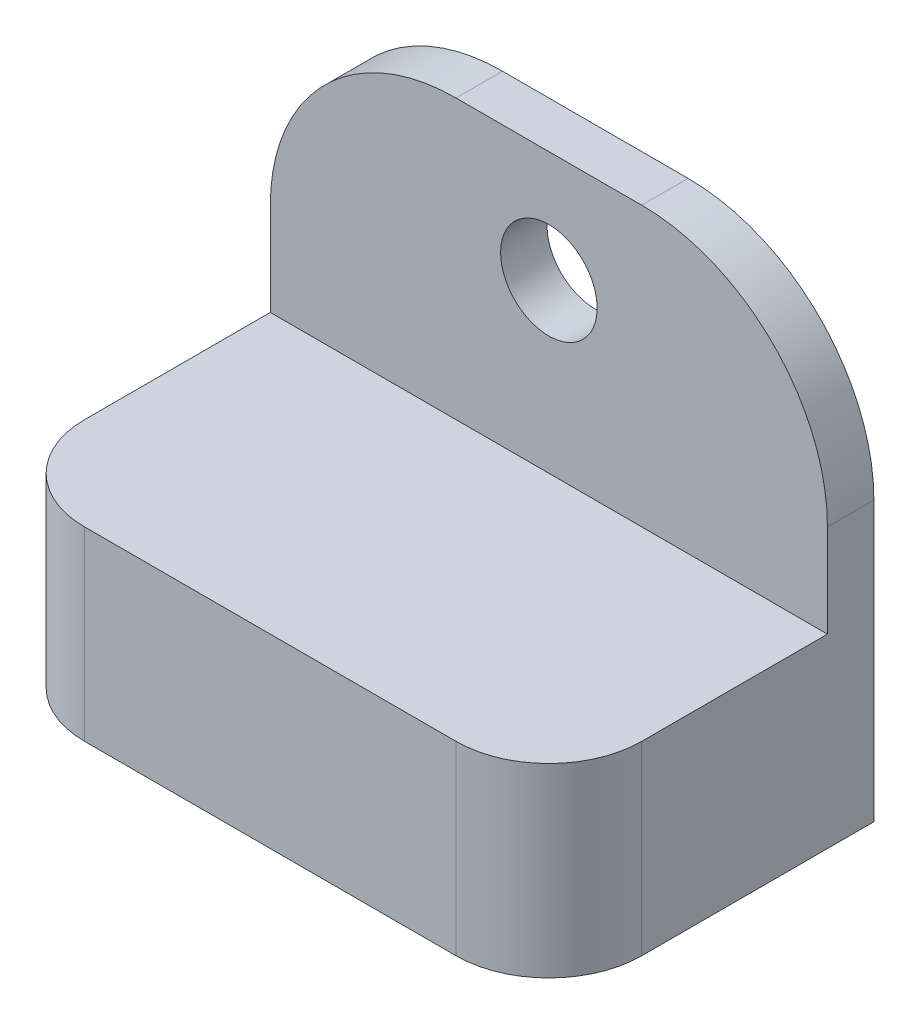
from build123d import *

# Parameters (mm, degrees)
BOSS_EXTRUDE1_DEPTH = 38.1
SKETCH3_R           = 3.302
CUT_EXTRUDE1_DEPTH  = 23.225
FILLET1_R           = 6.35
FILLET2_R           = 12.7


with BuildPart() as part:
    # Sketch1 → Boss-Extrude1 (new body)
    with BuildSketch(Plane(origin=(0, 0, 0), x_dir=(0, 0, -1), z_dir=(1, 0, 0))):
        Polygon((0, 0), (-22.225, 0), (-22.225, 12.7), (-3.175, 12.7), (-3.175, 31.75), (0, 31.75), align=None)
    extrude(amount=BOSS_EXTRUDE1_DEPTH)

    # Sketch3 → Cut-Extrude1 (cut, through all)
    with BuildSketch(Plane(origin=(0, 0, 0), x_dir=(-1, 0, 0), z_dir=(0, 0, -1))):
        with Locations((-19.05, 24.13)):
            Circle(SKETCH3_R)
    extrude(amount=-CUT_EXTRUDE1_DEPTH, mode=Mode.SUBTRACT)

    # Fillet1
    fillet1_edges = [part.edges().sort_by_distance(p)[0] for p in [
        (38.1, 6.35, 22.225),
        (0, 6.35, 22.225),
    ]]
    fillet(fillet1_edges, radius=FILLET1_R)

    # Fillet2
    fillet2_edges = [part.edges().sort_by_distance(p)[0] for p in [
        (0, 31.75, 1.5875),
        (38.1, 31.75, 1.5875),
    ]]
    fillet(fillet2_edges, radius=FILLET2_R)


solid = part.part
